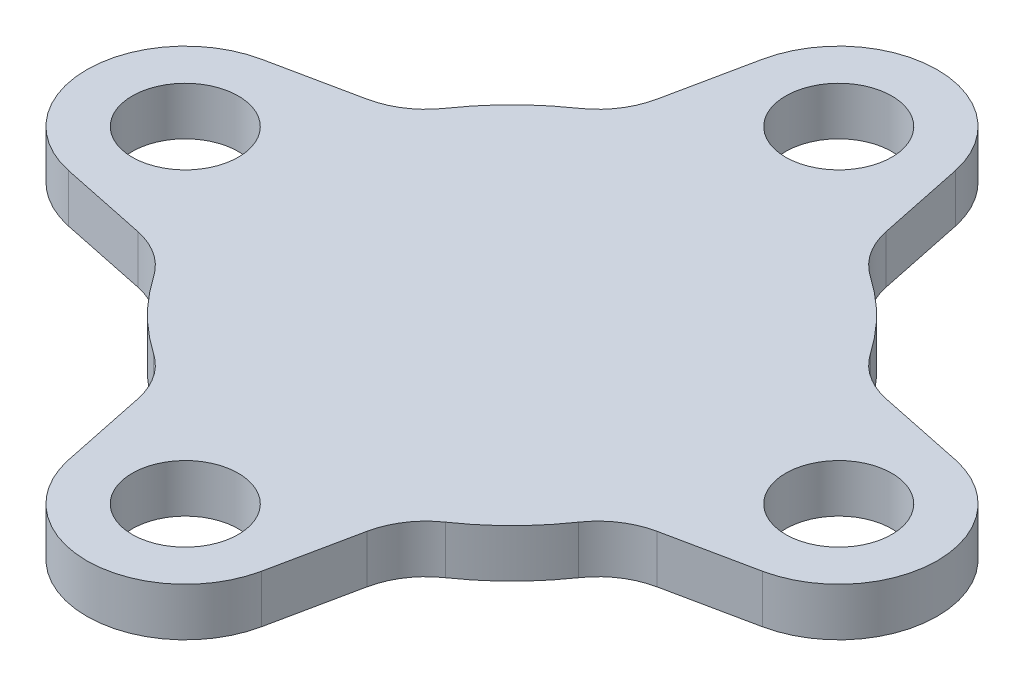
from build123d import *

# Parameters (mm, degrees)
SKETCH1_R           = 3.5
BOSS_EXTRUDE1_DEPTH = 3.175


with BuildPart() as part:
    # Sketch1 → Boss-Extrude1 (new body)
    with BuildSketch(Plane(origin=(0, 0, 0), x_dir=(1, 0, 0), z_dir=(0, 1, 0))):
        with BuildLine():
            Line((-7.559940761, 17.117095983), (-6.363973726, 22.870814531))
            ThreePointArc((-6.363973726, 22.870814531), (0, 28.04799995), (6.363973726, 22.870814531))
            Line((6.363973726, 22.870814531), (7.559940761, 17.117095983))
            ThreePointArc((7.559940761, 17.117095983), (8.292150293, 15.365504727), (9.624553992, 14.013135283))
            ThreePointArc((9.624553992, 14.013135283), (12.02081528, 12.02081528), (14.013135283, 9.624553992))
            ThreePointArc((14.013135283, 9.624553992), (15.365504727, 8.292150293), (17.117095983, 7.559940761))
            Line((17.117095983, 7.559940761), (22.870814531, 6.363973726))
            ThreePointArc((22.870814531, 6.363973726), (28.04799995, 0), (22.870814531, -6.363973726))
            Line((22.870814531, -6.363973726), (17.117095983, -7.559940761))
            ThreePointArc((17.117095983, -7.559940761), (15.365504727, -8.292150293), (14.013135283, -9.624553992))
            ThreePointArc((14.013135283, -9.624553992), (12.02081528, -12.02081528), (9.624553992, -14.013135283))
            ThreePointArc((9.624553992, -14.013135283), (8.292150293, -15.365504727), (7.559940761, -17.117095983))
            Line((7.559940761, -17.117095983), (6.363973726, -22.870814531))
            ThreePointArc((6.363973726, -22.870814531), (0, -28.04799995), (-6.363973726, -22.870814531))
            Line((-6.363973726, -22.870814531), (-7.559940761, -17.117095983))
            ThreePointArc((-7.559940761, -17.117095983), (-8.292150293, -15.365504727), (-9.624553992, -14.013135283))
            ThreePointArc((-9.624553992, -14.013135283), (-12.02081528, -12.02081528), (-14.013135283, -9.624553992))
            ThreePointArc((-14.013135283, -9.624553992), (-15.365504727, -8.292150293), (-17.117095983, -7.559940761))
            Line((-17.117095983, -7.559940761), (-22.870814531, -6.363973726))
            ThreePointArc((-22.870814531, -6.363973726), (-28.04799995, 0), (-22.870814531, 6.363973726))
            Line((-22.870814531, 6.363973726), (-17.117095983, 7.559940761))
            ThreePointArc((-17.117095983, 7.559940761), (-15.365504727, 8.292150293), (-14.013135283, 9.624553992))
            ThreePointArc((-14.013135283, 9.624553992), (-12.02081528, 12.02081528), (-9.624553992, 14.013135283))
            ThreePointArc((-9.624553992, 14.013135283), (-8.292150293, 15.365504727), (-7.559940761, 17.117095983))
        make_face()
        with Locations((0, 21.54799995)):
            Circle(SKETCH1_R, mode=Mode.SUBTRACT)
        with Locations((21.54799995, 0)):
            Circle(SKETCH1_R, mode=Mode.SUBTRACT)
        with Locations((0, -21.54799995)):
            Circle(SKETCH1_R, mode=Mode.SUBTRACT)
        with Locations((-21.54799995, 0)):
            Circle(SKETCH1_R, mode=Mode.SUBTRACT)
    extrude(amount=BOSS_EXTRUDE1_DEPTH)


solid = part.part
